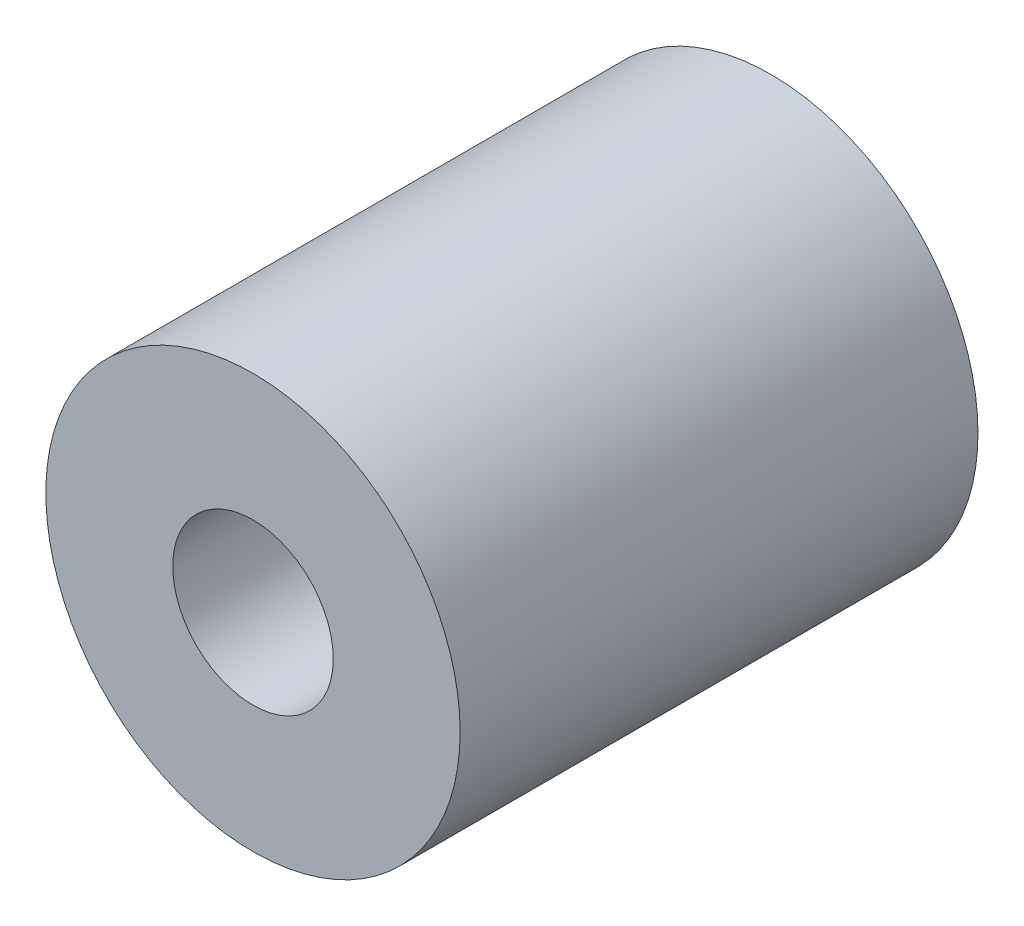
from build123d import *

# Parameters (mm, degrees)
SKETCH_1_R      = 8
SKETCH_1_R_2    = 3.1
EXTRUDE_1_DEPTH = 10


with BuildPart() as part:
    # 草图1 → 凸台-拉伸1 (new body, symmetric)
    with BuildSketch(Plane.XY):
        Circle(SKETCH_1_R)
        Circle(SKETCH_1_R_2, mode=Mode.SUBTRACT)
    extrude(amount=EXTRUDE_1_DEPTH, both=True)


solid = part.part
